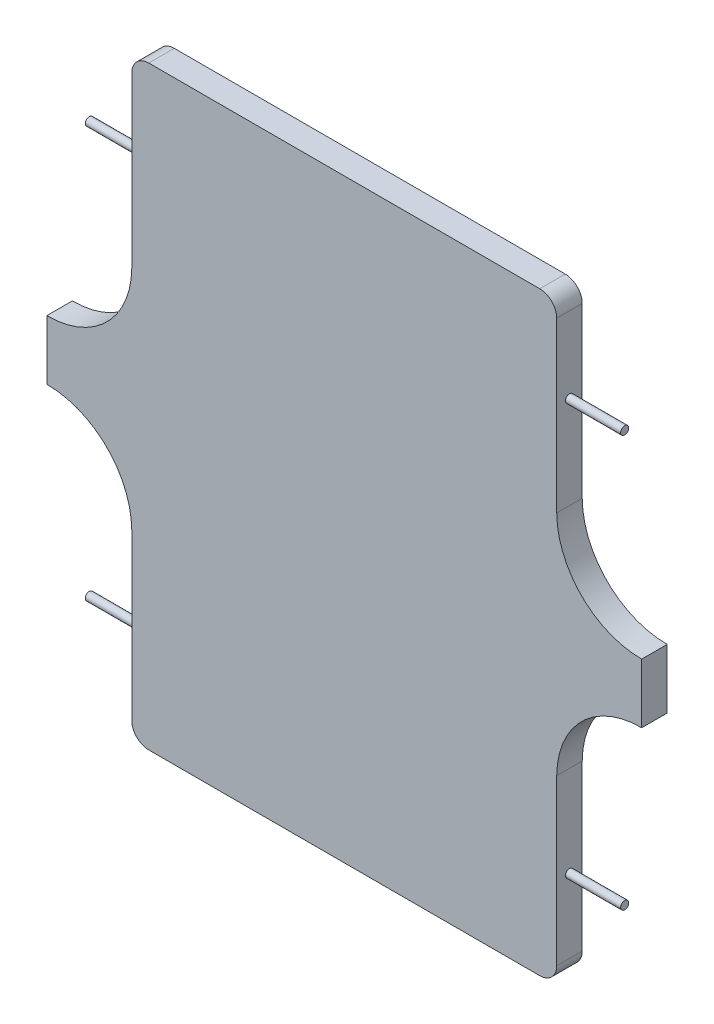
from build123d import *

# Parameters (mm, degrees)
ESTRUSIONE_ESTRUSIONE2_DEPTH = 30
SCHIZZO3D1_R                 = 4.75
ESTRUSIONE_ESTRUSIONE7_DEPTH = 65
SCHIZZO3D1_5_R               = 4.75
ESTRUSIONE_ESTRUSIONE8_DEPTH = 65
RACCORDO3_R                  = 20
RACCORDO4_R                  = 20
RACCORDO5_R                  = 20
RACCORDO6_R                  = 20


with BuildPart() as part:
    # Schizzo1 → Estrusione-Estrusione2 (new body)
    with BuildSketch(Plane.XY):
        with BuildLine():
            Line((-49.46854998, 22.257563415), (450.53145002, 22.257563415))
            Line((450.53145002, 22.257563415), (450.53145002, -196.304936585))
            ThreePointArc((450.53145002, -196.304936585), (480.066711204, -266.421864704), (550.53145002, -295.117436585))
            Line((550.53145002, -295.117436585), (550.53145002, -365.117436585))
            ThreePointArc((550.53145002, -365.117436585), (480.066711204, -393.813008466), (450.53145002, -463.929936585))
            Line((450.53145002, -463.929936585), (450.53145002, -677.742436585))
            Line((450.53145002, -677.742436585), (-49.46854998, -677.742436585))
            Line((-49.46854998, -677.742436585), (-49.46854998, -463.929936585))
            ThreePointArc((-49.46854998, -463.929936585), (-79.003811164, -393.813008466), (-149.46854998, -365.117436585))
            Line((-149.46854998, -365.117436585), (-149.46854998, -295.117436585))
            ThreePointArc((-149.46854998, -295.117436585), (-79.003811164, -266.421864704), (-49.46854998, -196.304936585))
            Line((-49.46854998, -196.304936585), (-49.46854998, 22.257563415))
        make_face()
    extrude(amount=ESTRUSIONE_ESTRUSIONE2_DEPTH)

    # Schizzo3D1 → Estrusione-Estrusione7 (add)
    with BuildSketch(Plane(origin=(-114.46854998, -87.023686585, 15), x_dir=(0, -1, 0), z_dir=(-1, 0, 0))):
        with Locations(Location((0, 0, 0), (0, 0, 270))):
            Circle(SCHIZZO3D1_R)
        with Locations(Location((483.8125, 0, 0), (0, 0, 270))):
            Circle(SCHIZZO3D1_R)
    extrude(amount=-ESTRUSIONE_ESTRUSIONE7_DEPTH)

    # Schizzo3D1_5 → Estrusione-Estrusione8 (add)
    with BuildSketch(Plane(origin=(515.53145002, -87.023686585, 15), x_dir=(0, -1, 0), z_dir=(-1, 0, 0))):
        with Locations(Location((0, 0, 0), (0, 0, 270))):
            Circle(SCHIZZO3D1_5_R)
        with Locations(Location((483.8125, 0, 0), (0, 0, 270))):
            Circle(SCHIZZO3D1_5_R)
    extrude(amount=ESTRUSIONE_ESTRUSIONE8_DEPTH)

    # Raccordo3
    raccordo3_edges = [part.edges().sort_by_distance(p)[0] for p in [
        (-49.46854998, 22.257563415, 15),
    ]]
    fillet(raccordo3_edges, radius=RACCORDO3_R)

    # Raccordo4
    raccordo4_edges = [part.edges().sort_by_distance(p)[0] for p in [
        (450.53145002, 22.257563415, 15),
    ]]
    fillet(raccordo4_edges, radius=RACCORDO4_R)

    # Raccordo5
    raccordo5_edges = [part.edges().sort_by_distance(p)[0] for p in [
        (450.53145002, -677.742436585, 15),
    ]]
    fillet(raccordo5_edges, radius=RACCORDO5_R)

    # Raccordo6
    raccordo6_edges = [part.edges().sort_by_distance(p)[0] for p in [
        (-49.46854998, -677.742436585, 15),
    ]]
    fillet(raccordo6_edges, radius=RACCORDO6_R)


solid = part.part
